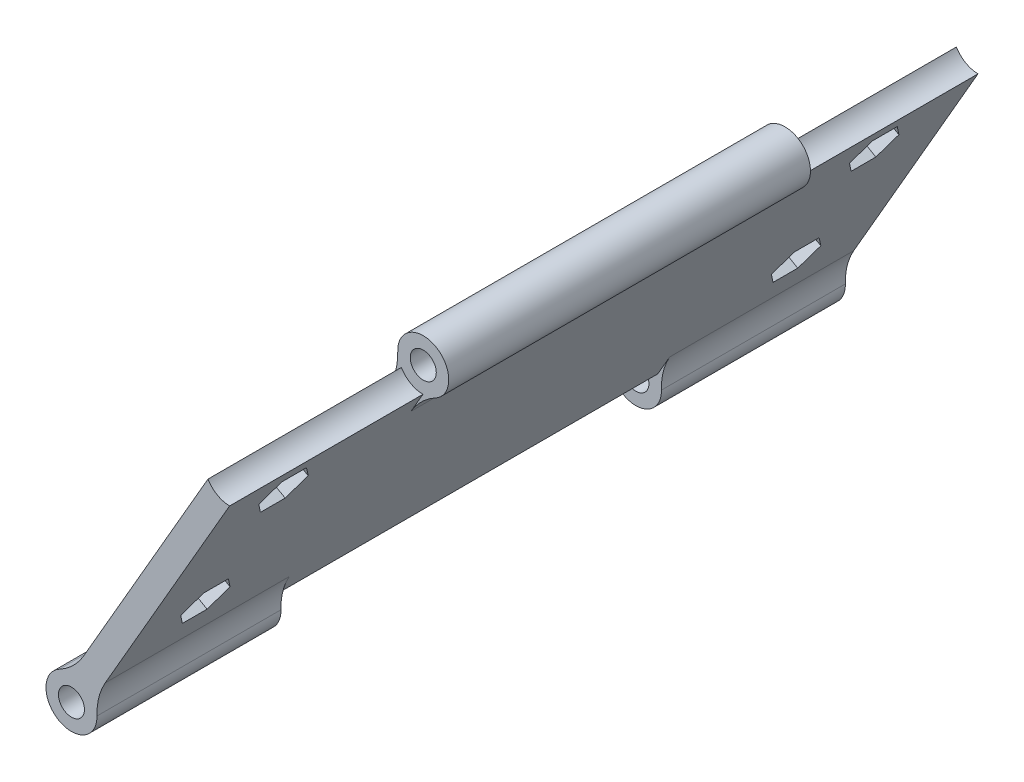
from build123d import *

# Parameters (mm, degrees)
SKETCH2_R               = 1.5875
BOSS_EXTRUDE1_DEPTH     = 10
BOSS_EXTRUDE2_DEPTH     = 120
SKETCH4_R               = 4.0875
CUT_EXTRUDE1_DEPTH      = 30.5
CUT_EXTRUDE1_DEPTH_BACK = 30.5
SKETCH5_R               = 4.0875
CUT_EXTRUDE2_DEPTH      = 31
SKETCH6_R               = 4.0875
CUT_EXTRUDE3_DEPTH      = 31
FILLET1_R               = 10
SKETCH7_R               = 1.75
CUT_EXTRUDE4_DEPTH      = 4
CUT_EXTRUDE5_DEPTH      = 2.25


with BuildPart() as part:
    # Sketch2 → Boss-Extrude1 (new body)
    with BuildSketch(Plane.XY):
        with BuildLine():
            Line((0, -27.7495), (0, 0))
            Line((0, 0), (38.1, 0))
            ThreePointArc((38.1, 0), (-26.940768363, 26.940768363), (0, -38.1))
            Line((0, -38.1), (0, -30.9245))
            ThreePointArc((0, -30.9245), (-1.5875, -29.337), (0, -27.7495))
        make_face()
        with Locations((-25.406587271, 14.6685)):
            Circle(SKETCH2_R, mode=Mode.SUBTRACT)
        with Locations((25.406587271, 14.6685)):
            Circle(SKETCH2_R, mode=Mode.SUBTRACT)
        with BuildLine():
            Line((38.1, 0), (0, 0))
            Line((0, 0), (0, -27.7495))
            ThreePointArc((0, -27.7495), (1.122532015, -28.214467985), (1.5875, -29.337))
            ThreePointArc((1.5875, -29.337), (1.122532015, -30.459532015), (0, -30.9245))
            Line((0, -30.9245), (0, -38.1))
            ThreePointArc((0, -38.1), (26.940768363, -26.940768363), (38.1, 0))
        make_face()
    extrude(amount=BOSS_EXTRUDE1_DEPTH)


with BuildPart() as body_2:
    # Sketch3 → Boss-Extrude2 (new body)
    with BuildSketch(Plane.XY.offset(10)):
        with BuildLine():
            ThreePointArc((29.494087271, 14.6685), (24.324372064, 18.610132466), (21.892146477, 12.581309985))
            Line((21.892146477, 12.581309985), (23.37551462, 15.150578976))
            ThreePointArc((23.37551462, 15.150578976), (25.649272347, 16.741845172), (27.494087271, 14.6685))
            ThreePointArc((27.494087271, 14.6685), (27.323499399, 13.841998855), (26.839616236, 13.150578976))
            Line((26.839616236, 13.150578976), (25.356248092, 10.581309985))
            ThreePointArc((25.356248092, 10.581309985), (28.279033516, 11.760457906), (29.494087271, 14.6685))
        make_face()
        with BuildLine():
            Line((24.362837271, 12.86067197), (23.362837271, 11.128621162))
            ThreePointArc((23.362837271, 11.128621162), (24.324372064, 10.726867534), (25.356248092, 10.581309985))
            Line((25.356248092, 10.581309985), (26.839616236, 13.150578976))
            ThreePointArc((26.839616236, 13.150578976), (25.649272347, 12.595154828), (24.362837271, 12.86067197))
        make_face()
        with BuildLine():
            ThreePointArc((21.892146477, 12.581309985), (22.534141026, 11.760457906), (23.362837271, 11.128621162))
            Line((23.362837271, 11.128621162), (24.362837271, 12.86067197))
            ThreePointArc((24.362837271, 12.86067197), (23.489675143, 13.841998855), (23.37551462, 15.150578976))
            Line((23.37551462, 15.150578976), (21.892146477, 12.581309985))
        make_face()
        with BuildLine():
            Line((23.362837271, 11.128621162), (2.04375, -25.797121162))
            ThreePointArc((2.04375, -25.797121162), (2.872446245, -26.428957906), (3.514440794, -27.249809985))
            Line((3.514440794, -27.249809985), (25.356248092, 10.581309985))
            ThreePointArc((25.356248092, 10.581309985), (24.324372064, 10.726867534), (23.362837271, 11.128621162))
        make_face()
        with BuildLine():
            ThreePointArc((0.050339179, -25.249809985), (1.082215206, -25.395367534), (2.04375, -25.797121162))
            Line((2.04375, -25.797121162), (23.362837271, 11.128621162))
            ThreePointArc((23.362837271, 11.128621162), (22.534141026, 11.760457906), (21.892146477, 12.581309985))
            Line((21.892146477, 12.581309985), (0.050339179, -25.249809985))
        make_face()
        with BuildLine():
            ThreePointArc((-1.433028965, -27.819078976), (-0.242685076, -27.263654828), (1.04375, -27.52917197))
            Line((1.04375, -27.52917197), (2.04375, -25.797121162))
            ThreePointArc((2.04375, -25.797121162), (1.082215206, -25.395367534), (0.050339179, -25.249809985))
            Line((0.050339179, -25.249809985), (-1.433028965, -27.819078976))
        make_face()
        with BuildLine():
            Line((2.04375, -25.797121162), (1.04375, -27.52917197))
            ThreePointArc((1.04375, -27.52917197), (1.80782803, -28.29325), (2.0875, -29.337))
            ThreePointArc((2.0875, -29.337), (2.073345172, -29.579685076), (2.03107265, -29.819078976))
            Line((2.03107265, -29.819078976), (3.514440794, -27.249809985))
            ThreePointArc((3.514440794, -27.249809985), (2.872446245, -26.428957906), (2.04375, -25.797121162))
        make_face()
        with BuildLine():
            ThreePointArc((2.03107265, -29.819078976), (-1.04375, -31.14482803), (-1.433028965, -27.819078976))
            Line((-1.433028965, -27.819078976), (0.050339179, -25.249809985))
            ThreePointArc((0.050339179, -25.249809985), (-2.908042094, -32.209446245), (4.0875, -29.337))
            ThreePointArc((4.0875, -29.337), (3.941632466, -28.254784794), (3.514440794, -27.249809985))
            Line((3.514440794, -27.249809985), (2.03107265, -29.819078976))
        make_face()
    extrude(amount=BOSS_EXTRUDE2_DEPTH)

    # Sketch4 → Cut-Extrude1 (cut, two sides)
    with BuildSketch(Plane.XY.offset(70)) as cut_extrude1_sk:
        with Locations((0, -29.337)):
            Circle(SKETCH4_R)
    extrude(amount=CUT_EXTRUDE1_DEPTH, mode=Mode.SUBTRACT)
    extrude(cut_extrude1_sk.sketch, amount=-CUT_EXTRUDE1_DEPTH_BACK, mode=Mode.SUBTRACT)

    # Sketch5 → Cut-Extrude2 (cut)
    with BuildSketch(Plane(origin=(0, 0, 10), x_dir=(-1, 0, 0), z_dir=(0, 0, -1))):
        with Locations((-25.406587271, 14.6685)):
            Circle(SKETCH5_R)
    extrude(amount=-CUT_EXTRUDE2_DEPTH, mode=Mode.SUBTRACT)

    # Sketch6 → Cut-Extrude3 (cut)
    with BuildSketch(Plane.XY.offset(130)):
        with Locations((25.406587271, 14.6685)):
            Circle(SKETCH6_R)
    extrude(amount=-CUT_EXTRUDE3_DEPTH, mode=Mode.SUBTRACT)

    # Fillet1
    fillet1_edges = [body_2.edges().sort_by_distance(p)[0] for p in [
        (0.050339179, -25.249809985, 115.25),
        (3.514440794, -27.249809985, 115.25),
        (0.050339179, -25.249809985, 24.75),
        (3.514440794, -27.249809985, 24.75),
        (21.892146477, 12.581309985, 70),
        (25.356248092, 10.581309985, 70),
    ]]
    fillet(fillet1_edges, radius=FILLET1_R)

    # Sketch7 → Cut-Extrude4 (cut)
    with BuildSketch(Plane(origin=(10.971242828, -6.33425, 0), x_dir=(0, 0, 1), z_dir=(-0.866025404, 0.5, 0))):
        with Locations((23.771980031, -8.948916416)):
            Circle(SKETCH7_R)
        with Locations((23.771980031, 16.095483584)):
            Circle(SKETCH7_R)
        with Locations((118.488580031, 16.095483584)):
            Circle(SKETCH7_R)
        with Locations((118.488580031, -8.948916416)):
            Circle(SKETCH7_R)
    extrude(amount=-CUT_EXTRUDE4_DEPTH, mode=Mode.SUBTRACT)

    # Sketch8 → Cut-Extrude5 (cut)
    with BuildSketch(Plane(origin=(14.435344443, -8.33425, 0), x_dir=(0, 0, -1), z_dir=(0.866025404, -0.5, 0))):
        Polygon((-19.812511885, 16.095483584), (-21.792245958, 19.524483584), (-25.751714104, 19.524483584), (-27.731448177, 16.095483584), (-25.751714104, 12.666483584), (-21.792245958, 12.666483584), align=None)
        Polygon((-19.812511885, -8.948916416), (-21.792245958, -5.519916416), (-25.751714104, -5.519916416), (-27.731448177, -8.948916416), (-25.751714104, -12.377916416), (-21.792245958, -12.377916416), align=None)
        Polygon((-114.529111885, 16.095483584), (-116.508845958, 19.524483584), (-120.468314104, 19.524483584), (-122.448048177, 16.095483584), (-120.468314104, 12.666483584), (-116.508845958, 12.666483584), align=None)
        Polygon((-114.529111885, -8.948916416), (-116.508845958, -5.519916416), (-120.468314104, -5.519916416), (-122.448048177, -8.948916416), (-120.468314104, -12.377916416), (-116.508845958, -12.377916416), align=None)
    extrude(amount=-CUT_EXTRUDE5_DEPTH, mode=Mode.SUBTRACT)


solid = body_2.part
